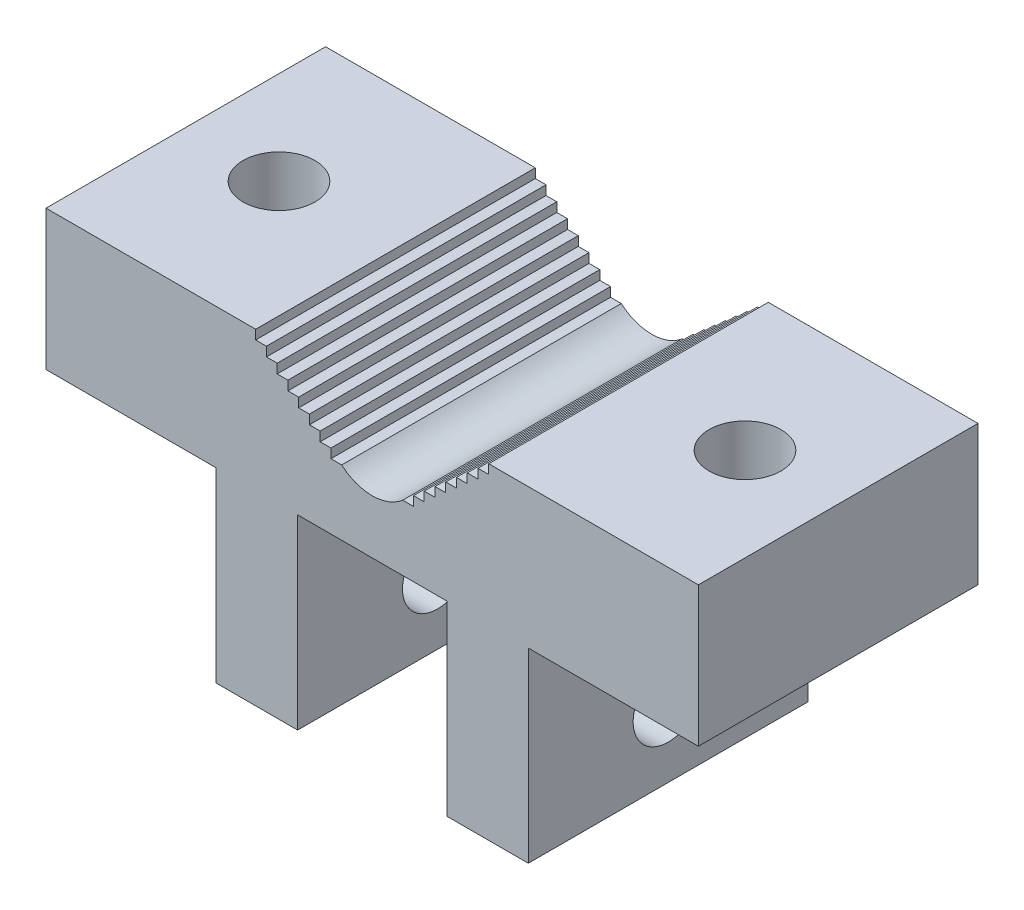
from build123d import *

# Parameters (mm, degrees)
SKETCH1_W                    = 88.9
SKETCH1_H                    = 19.05
BOSS_EXTRUDE1_DEPTH          = 38.1
CUT_EXTRUDE1_REACH           = 40.1
F_3_8_CLEARANCE_HOLE1_D      = 9.8044
SKETCH7_W                    = 11.1125
SKETCH7_H                    = 38.1
BOSS_EXTRUDE2_DEPTH          = 25.4
F_3_8_0_375_DIAMETER_HOLE1_D = 9.525


with BuildPart() as part:
    # Sketch1 → Boss-Extrude1 (new body)
    with BuildSketch(Plane.XY):
        with Locations((0, 9.525)):
            Rectangle(SKETCH1_W, SKETCH1_H)
    extrude(amount=-BOSS_EXTRUDE1_DEPTH)

    # Sketch2 → Cut-Extrude1 (cut, up to next)
    with BuildSketch(Plane.XY, mode=Mode.PRIVATE) as cut_extrude1_sk1:
        with BuildLine():
            Line((-15.875, 19.05), (0, 19.05))
            Line((0, 19.05), (15.875, 19.05))
            Line((15.875, 19.05), (15.875, 17.78))
            Line((15.875, 17.78), (14.410694861, 17.78))
            Line((14.410694861, 17.78), (14.410694861, 16.51))
            Line((14.410694861, 16.51), (12.946389723, 16.51))
            Line((12.946389723, 16.51), (12.946389723, 15.24))
            Line((12.946389723, 15.24), (11.482084584, 15.24))
            Line((11.482084584, 15.24), (11.482084584, 13.97))
            Line((11.482084584, 13.97), (10.017779445, 13.97))
            Line((10.017779445, 13.97), (10.017779445, 12.7))
            Line((10.017779445, 12.7), (8.553474306, 12.7))
            Line((8.553474306, 12.7), (8.553474306, 11.43))
            Line((8.553474306, 11.43), (7.089169168, 11.43))
            Line((7.089169168, 11.43), (7.089169168, 10.16))
            Line((7.089169168, 10.16), (5.624864029, 10.16))
            Line((5.624864029, 10.16), (5.624864029, 8.89))
            Line((5.624864029, 8.89), (4.16055889, 8.89))
            ThreePointArc((4.16055889, 8.89), (0, 7.337108475), (-4.16055889, 8.89))
            Line((-4.16055889, 8.89), (-5.624864029, 8.89))
            Line((-5.624864029, 8.89), (-5.624864029, 10.16))
            Line((-5.624864029, 10.16), (-7.089169168, 10.16))
            Line((-7.089169168, 10.16), (-7.089169168, 11.43))
            Line((-7.089169168, 11.43), (-8.553474306, 11.43))
            Line((-8.553474306, 11.43), (-8.553474306, 12.7))
            Line((-8.553474306, 12.7), (-10.017779445, 12.7))
            Line((-10.017779445, 12.7), (-10.017779445, 13.97))
            Line((-10.017779445, 13.97), (-11.482084584, 13.97))
            Line((-11.482084584, 13.97), (-11.482084584, 15.24))
            Line((-11.482084584, 15.24), (-12.946389723, 15.24))
            Line((-12.946389723, 15.24), (-12.946389723, 16.51))
            Line((-12.946389723, 16.51), (-14.410694861, 16.51))
            Line((-14.410694861, 16.51), (-14.410694861, 17.78))
            Line((-14.410694861, 17.78), (-15.875, 17.78))
            Line((-15.875, 17.78), (-15.875, 19.05))
        make_face()
    cut_extrude1_tool1 = extrude(cut_extrude1_sk1.sketch, amount=-CUT_EXTRUDE1_REACH, mode=Mode.PRIVATE) & part.part
    add(cut_extrude1_tool1.solids().sort_by_distance((0, 14.620592, 0))[0], mode=Mode.SUBTRACT)

    # 3/8 Clearance Hole1 (through all)
    with Locations(Plane(origin=(0, 19.05, 0), x_dir=(1, 0, 0), z_dir=(0, 1, 0))):
        with Locations((-31.75, 19.05), (31.75, 19.05)):
            Hole(F_3_8_CLEARANCE_HOLE1_D / 2)

    # Sketch7 → Boss-Extrude2 (add)
    with BuildSketch(Plane.XZ):
        with Locations((-15.71625, -19.05)):
            Rectangle(SKETCH7_W, SKETCH7_H)
        with Locations((15.71625, -19.05)):
            Rectangle(SKETCH7_W, SKETCH7_H)
    extrude(amount=BOSS_EXTRUDE2_DEPTH)

    # 3/8 (0.375) Diameter Hole1 (through all)
    with Locations(Plane(origin=(21.2725, 0, 0), x_dir=(0, 0, -1), z_dir=(1, 0, 0))):
        with Locations((19.05, -15.875)):
            Hole(F_3_8_0_375_DIAMETER_HOLE1_D / 2)


solid = part.part
